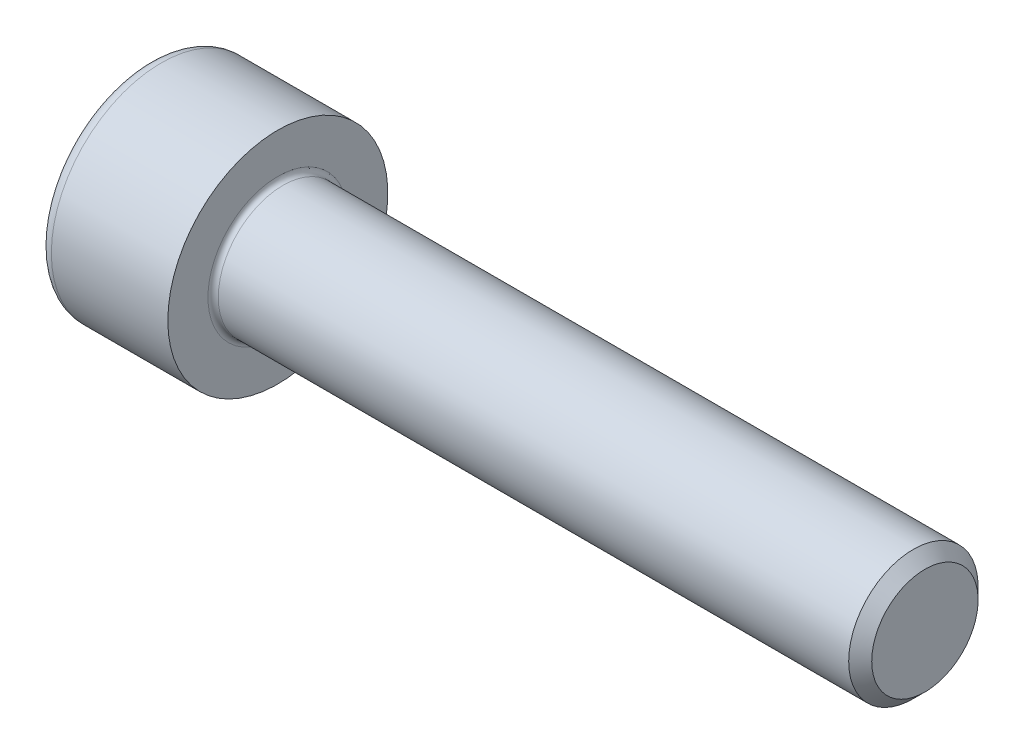
from build123d import *

# Parameters (mm, degrees)
FILLET1_R   = 0.2
FILLET2_R   = 0.5
HEX_2_DEPTH = 2.5


with BuildPart() as part:
    # BodySke → Base-Revolve (revolve)
    with BuildSketch(Plane.XY):
        Polygon((0, 0), (0, 4.25), (5, 4.25), (5, 2.5), (29.555, 2.5), (30, 2.055), (30, 0), align=None)
    revolve(axis=Axis((-31.75, 0, 0), (1, 0, 0)))

    # Fillet1
    fillet1_edges = [part.edges().sort_by_distance(p)[0] for p in [
        (5, -2.5, 0),
    ]]
    fillet(fillet1_edges, radius=FILLET1_R)

    # Fillet2
    fillet2_edges = [part.edges().sort_by_distance(p)[0] for p in [
        (0, -4.25, 0),
    ]]
    fillet(fillet2_edges, radius=FILLET2_R)

    # Sketch2 → Hex-PreBroach (revolve, cut)
    with BuildSketch(Plane.XY):
        Polygon((0, 2.01), (2.5, 2.01), (3.660474041, 0), (0, 0), align=None)
    revolve(axis=Axis((0, 0, 0), (1, 0, 0)), mode=Mode.SUBTRACT)

    # Sketch3 → Hex 2 (cut)
    with BuildSketch(Plane(origin=(0, 0, 0), x_dir=(0, 0.5, 0.866025404), z_dir=(-1, 0, 0))):
        Polygon((1.160474041, 2.01), (-1.160474041, 2.01), (-2.320948082, 0), (-1.160474041, -2.01), (1.160474041, -2.01), (2.320948082, 0), align=None)
    extrude(amount=-HEX_2_DEPTH, mode=Mode.SUBTRACT)


solid = part.part
